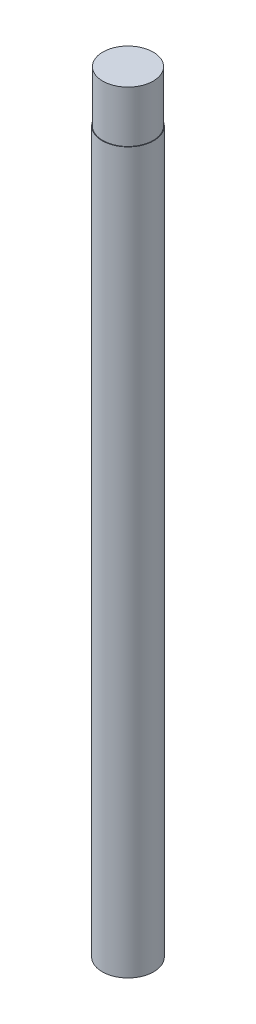
from build123d import *

# Parameters (mm, degrees)
SKETCH1_R           = 5
BOSS_EXTRUDE1_DEPTH = 150
SKETCH2_R           = 5
SKETCH2_R_2         = 4.9
CUT_EXTRUDE1_DEPTH  = 10


with BuildPart() as part:
    # Sketch1 → Boss-Extrude1 (new body)
    with BuildSketch(Plane(origin=(0, 0, 0), x_dir=(1, 0, 0), z_dir=(0, 1, 0))):
        Circle(SKETCH1_R)
    extrude(amount=BOSS_EXTRUDE1_DEPTH)

    # Sketch2 → Cut-Extrude1 (cut)
    with BuildSketch(Plane(origin=(0, 150, 0), x_dir=(1, 0, 0), z_dir=(0, 1, 0))):
        Circle(SKETCH2_R)
        Circle(SKETCH2_R_2, mode=Mode.SUBTRACT)
    extrude(amount=-CUT_EXTRUDE1_DEPTH, mode=Mode.SUBTRACT)


solid = part.part
